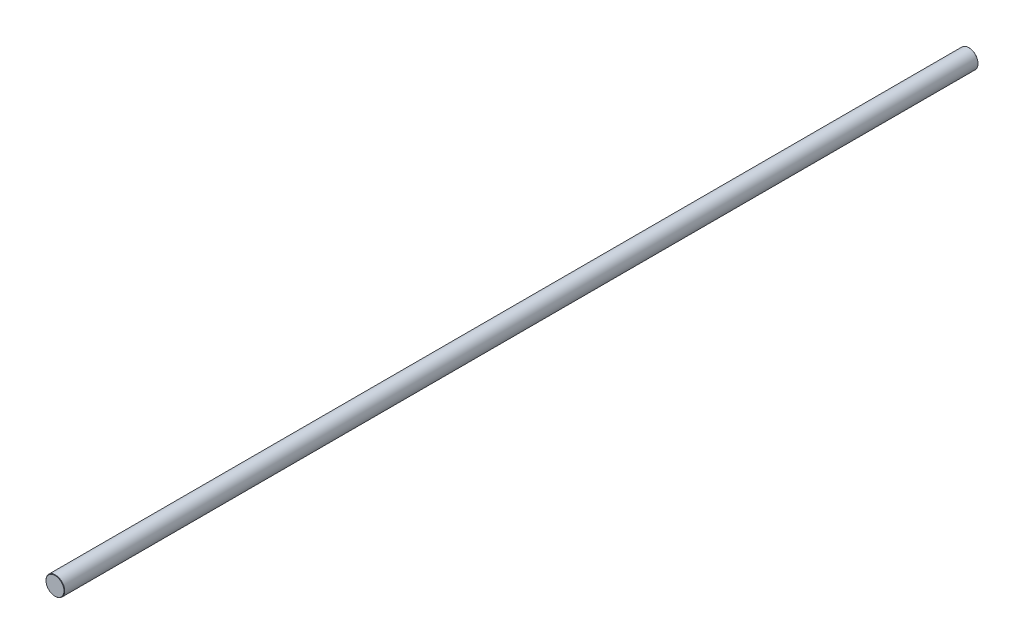
from build123d import *

# Parameters (mm, degrees)
SKETCH3_R                = 12.5
BOSS_EXTRUDE1_DEPTH      = 610
BOSS_EXTRUDE1_DEPTH_BACK = 610
CHAMFER1_SIZE            = 0.5


with BuildPart() as part:
    # Sketch3 → Boss-Extrude1 (new body, two sides)
    with BuildSketch(Plane.XY) as boss_extrude1_sk:
        Circle(SKETCH3_R)
    extrude(amount=BOSS_EXTRUDE1_DEPTH)
    extrude(boss_extrude1_sk.sketch, amount=-BOSS_EXTRUDE1_DEPTH_BACK)

    # Chamfer1
    chamfer1_edges = [part.edges().sort_by_distance(p)[0] for p in [
        (-12.5, 0, -610),
        (-12.5, 0, 610),
    ]]
    chamfer(chamfer1_edges, length=CHAMFER1_SIZE)


solid = part.part
